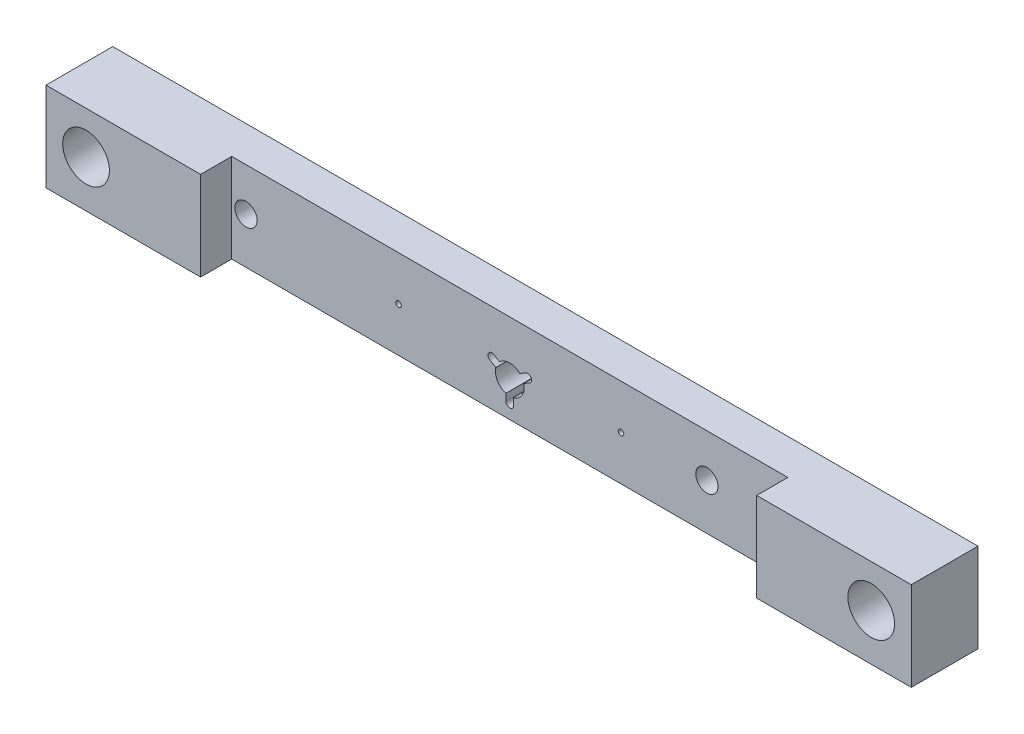
from build123d import *

# Parameters (mm, degrees)
SKETCH1_W                           = 389
SKETCH1_H                           = 39.998298848
SKETCH1_R                           = 10.5
SKETCH1_R_2                         = 6.35
MAIN_BODY_DEPTH                     = 30
Z_START                             = 16
SKETCH1_4_R                         = 10.25
SKETCH1_4_R_2                       = 6.35
Z_NUT_FLANGE_RECESS_DEPTH           = 20
SKETCH2_R                           = 1.25
LINEAR_BEARINGS_M3_PILOTS_DEPTH     = 5
SKETCH3_R                           = 6.35
Z_NUT_SCREW_THROUGH_HOLE_DEPTH      = 30
STEPPER_CUT_REACH                   = 403.624
SKETCH4_W                           = 250
SKETCH4_H                           = 21
M3_TAPPED_HOLE1_D                   = 2.5
M3_TAPPED_HOLE1_DEPTH               = 8.5
M3_TAPPED_HOLE1_TIP                 = 0.751075774
Z_NUT_SCREW_CLEARENCE_REACH         = 403.904
Z_NUT_SCREW_CLEARENCE_PATTERN_COUNT = 3
INSERT_THROUGH_HOLE_LOWER_G_REACH   = 403.904
SKETCH13_R                          = 5
CABLE_START                         = -16
SKETCH15_R                          = 1.25
CABLE_CLIPS_M3_PILOTS_DEPTH         = 418.904345655
M3_TAPPED_HOLE2_D                   = 2.5


with BuildPart() as part:
    # Sketch1 → Main Body (new body)
    with BuildSketch(Plane.XY):
        with Locations((-204, -22.719149424)):
            Rectangle(SKETCH1_W, SKETCH1_H)
        with Locations((-380.5, -21.75)):
            Circle(SKETCH1_R, mode=Mode.SUBTRACT)
        with Locations((-27.5, -21.75)):
            Circle(SKETCH1_R, mode=Mode.SUBTRACT)
        with Locations((-204, -27.1)):
            Circle(SKETCH1_R_2, mode=Mode.SUBTRACT)
    extrude(amount=MAIN_BODY_DEPTH)

    # Sketch1_4 → Z Nut Flange Recess (cut)
    with BuildSketch(Plane.XY.offset(Z_START)):
        with Locations((-204, -27.1)):
            Circle(SKETCH1_4_R)
        with Locations((-204, -27.1)):
            Circle(SKETCH1_4_R_2, mode=Mode.SUBTRACT)
        with Locations((-204, -27.1)):
            Circle(SKETCH1_4_R_2)
    extrude(amount=Z_NUT_FLANGE_RECESS_DEPTH, mode=Mode.SUBTRACT)

    # Sketch2 → Linear Bearings - M3 Pilots (cut)
    with BuildSketch(Plane(origin=(0, 0, 0), x_dir=(-1, 0, 0), z_dir=(0, 0, -1))):
        with Locations((16.186291501, -10.436291501)):
            Circle(SKETCH2_R)
        with Locations((38.813708499, -10.436291501)):
            Circle(SKETCH2_R)
        with Locations((16.186291501, -33.063708499)):
            Circle(SKETCH2_R)
        with Locations((38.813708499, -33.063708499)):
            Circle(SKETCH2_R)
        with Locations((369.186291501, -10.436291501)):
            Circle(SKETCH2_R)
        with Locations((391.813708499, -10.436291501)):
            Circle(SKETCH2_R)
        with Locations((369.186291501, -33.063708499)):
            Circle(SKETCH2_R)
        with Locations((391.813708499, -33.063708499)):
            Circle(SKETCH2_R)
    extrude(amount=-LINEAR_BEARINGS_M3_PILOTS_DEPTH, mode=Mode.SUBTRACT)

    # Sketch3 → Z Nut - Screw Through Hole (cut)
    with BuildSketch(Plane(origin=(0, 0, 0), x_dir=(-1, 0, 0), z_dir=(0, 0, -1))):
        with BuildLine():
            Line((205.55, -35.15), (205.55, -33.360990337))
            ThreePointArc((205.55, -33.360990337), (209.585863854, -30.325), (210.197176685, -25.311844207))
            Line((210.197176685, -25.311844207), (211.7465045, -24.417339376))
            ThreePointArc((211.7465045, -24.417339376), (212.313843876, -22.3), (210.1965045, -21.732660624))
            Line((210.1965045, -21.732660624), (208.647176685, -22.627165456))
            ThreePointArc((208.647176685, -22.627165456), (204, -20.65), (199.352823315, -22.627165456))
            Line((199.352823315, -22.627165456), (197.8034955, -21.732660624))
            ThreePointArc((197.8034955, -21.732660624), (195.686156124, -22.3), (196.2534955, -24.417339376))
            Line((196.2534955, -24.417339376), (197.802823315, -25.311844207))
            ThreePointArc((197.802823315, -25.311844207), (198.414136146, -30.325), (202.45, -33.360990337))
            Line((202.45, -33.360990337), (202.45, -35.15))
            ThreePointArc((202.45, -35.15), (204, -36.7), (205.55, -35.15))
        make_face()
        with Locations((204, -27.1)):
            Circle(SKETCH3_R, mode=Mode.SUBTRACT)
    extrude(amount=-Z_NUT_SCREW_THROUGH_HOLE_DEPTH, mode=Mode.SUBTRACT)

    # Sketch4 → Stepper Cut (cut, up to next)
    with BuildSketch(Plane(origin=(0, -2.72, 0), x_dir=(1, 0, 0), z_dir=(0, 1, 0)), mode=Mode.PRIVATE) as stepper_cut_sk1:
        with Locations((-204, -26.5)):
            Rectangle(SKETCH4_W, SKETCH4_H)
    stepper_cut_tool1 = extrude(stepper_cut_sk1.sketch, amount=-STEPPER_CUT_REACH, mode=Mode.PRIVATE) & part.part
    add(stepper_cut_tool1.solids().sort_by_distance((-204, -2.72, 26.5))[0], mode=Mode.SUBTRACT)

    # M3 Tapped Hole1
    with Locations(Plane(origin=(-16.186291501, -33.063708499, 0), x_dir=(-1, 0, 0), z_dir=(0, 0, -1))):
        with Locations((0, 0), (22.627416998, 0), (22.627416998, 22.627416998), (0, 22.627416998), (375.627416998, 22.627416998), (353, 22.627416998), (353, 0), (375.627416998, 0)):
            Hole(M3_TAPPED_HOLE1_D / 2, depth=M3_TAPPED_HOLE1_DEPTH)
            with Locations((0, 0, -(M3_TAPPED_HOLE1_DEPTH + M3_TAPPED_HOLE1_TIP / 2))):  # 118° drill point
                Cone(0, M3_TAPPED_HOLE1_D / 2, M3_TAPPED_HOLE1_TIP, mode=Mode.SUBTRACT)

    # Sketch12 → Z Nut Screw Clearence (cut, up to next)
    with BuildSketch(Plane(origin=(0, 0, 0), x_dir=(-1, 0, 0), z_dir=(0, 0, -1)), mode=Mode.PRIVATE) as z_nut_screw_clearence_sk1:
        with BuildLine():
            Line((205.75, -36.4), (205.75, -33.308059278))
            ThreePointArc((205.75, -33.308059278), (205.650212236, -33.335326742), (205.55, -33.360990337))
            Line((205.55, -33.360990337), (205.55, -35.15))
            ThreePointArc((205.55, -35.15), (204, -36.7), (202.45, -35.15))
            Line((202.45, -35.15), (202.45, -33.360990337))
            ThreePointArc((202.45, -33.360990337), (202.349787764, -33.335326742), (202.25, -33.308059278))
            Line((202.25, -33.308059278), (202.25, -36.4))
            ThreePointArc((202.25, -36.4), (204, -38.15), (205.75, -36.4))
        make_face()
    z_nut_screw_clearence_tool1 = extrude(z_nut_screw_clearence_sk1.sketch, amount=-Z_NUT_SCREW_CLEARENCE_REACH, mode=Mode.PRIVATE) & part.part
    z_nut_screw_clearence = z_nut_screw_clearence_tool1.solids().sort_by_distance((-202.309745, -34.85403, 0))[0]
    add(z_nut_screw_clearence, mode=Mode.SUBTRACT)

    # Z Nut Screw Clearence Pattern: Z Nut Screw Clearence ×3 about axis
    z_nut_screw_clearence_pattern_axis = Axis((-204, -27.1, 0), (0, 0, 1))
    for i in range(1, Z_NUT_SCREW_CLEARENCE_PATTERN_COUNT):
        add(z_nut_screw_clearence.rotate(z_nut_screw_clearence_pattern_axis, i * 360 / Z_NUT_SCREW_CLEARENCE_PATTERN_COUNT), mode=Mode.SUBTRACT)

    # Sketch13 → Insert Through Hole - Lower G (cut, up to next)
    with BuildSketch(Plane(origin=(0, 0, 0), x_dir=(-1, 0, 0), z_dir=(0, 0, -1)), mode=Mode.PRIVATE) as insert_through_hole_lower_g_sk1:
        with Locations((115.4, -22)):
            Circle(SKETCH13_R)
    insert_through_hole_lower_g_tool1 = extrude(insert_through_hole_lower_g_sk1.sketch, amount=-INSERT_THROUGH_HOLE_LOWER_G_REACH, mode=Mode.PRIVATE) & part.part
    # Sketch13 → Insert Through Hole - Lower G (cut, up to next)
    with BuildSketch(Plane(origin=(0, 0, 0), x_dir=(-1, 0, 0), z_dir=(0, 0, -1)), mode=Mode.PRIVATE) as insert_through_hole_lower_g_sk2:
        with Locations((322.6, -22)):
            Circle(SKETCH13_R)
    insert_through_hole_lower_g_tool2 = extrude(insert_through_hole_lower_g_sk2.sketch, amount=-INSERT_THROUGH_HOLE_LOWER_G_REACH, mode=Mode.PRIVATE) & part.part
    add(insert_through_hole_lower_g_tool1.solids().sort_by_distance((-115.4, -22, 0))[0], mode=Mode.SUBTRACT)
    add(insert_through_hole_lower_g_tool2.solids().sort_by_distance((-322.6, -22, 0))[0], mode=Mode.SUBTRACT)

    # Sketch15 → Cable Clips - M3 Pilots (cut, through all)
    with BuildSketch(Plane(origin=(0, 0, 0), x_dir=(-1, 0, 0), z_dir=(0, 0, -1)).offset(CABLE_START)):
        with Locations(Location((154, -22.719149424, 0), (0, 0, 180))):
            Circle(SKETCH15_R)
        with Locations(Location((254, -22.719149424, 0), (0, 0, 180))):
            Circle(SKETCH15_R)
    extrude(amount=CABLE_CLIPS_M3_PILOTS_DEPTH, mode=Mode.SUBTRACT)

    # M3 Tapped Hole2 (through all)
    with Locations(Plane(origin=(-154, -22.719149424, 16), x_dir=(1, 0, 0), z_dir=(0, 0, 1))):
        with Locations((0, 0), (-100, 0)):
            Hole(M3_TAPPED_HOLE2_D / 2)


solid = part.part
